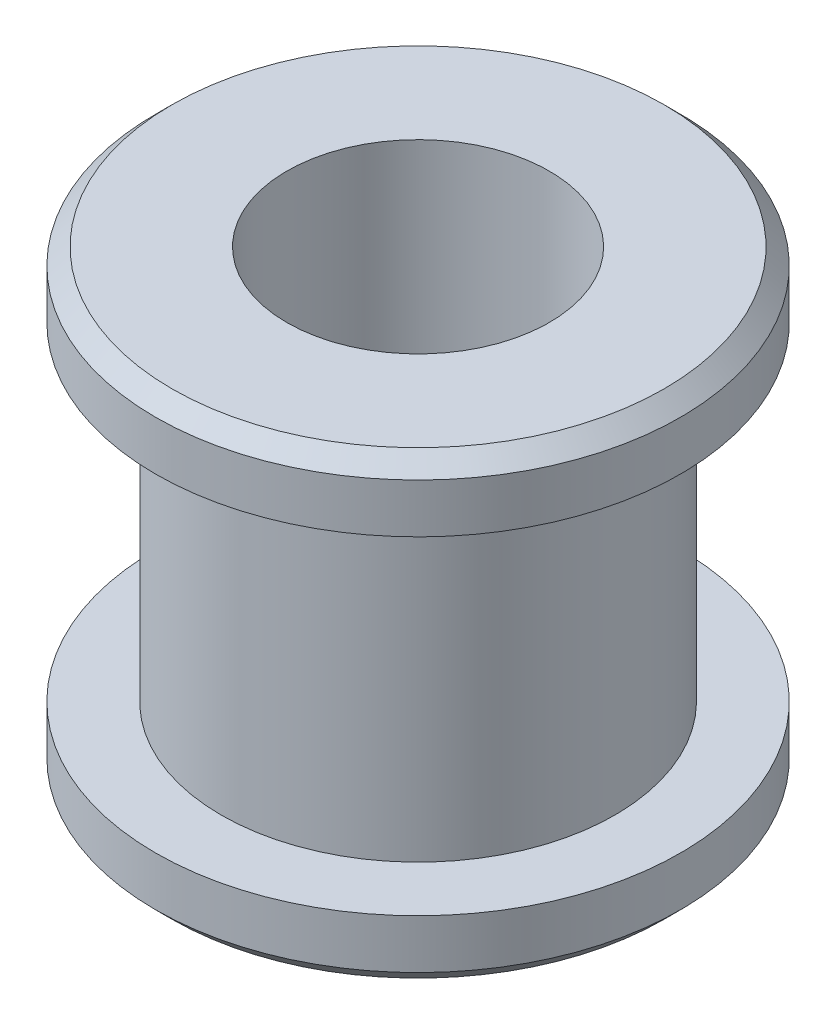
from build123d import *

# Parameters (mm, degrees)
BOSS_EXTRUDE1_DEPTH      = 12
BOSS_EXTRUDE1_DEPTH_BACK = 2
SKETCH1_R                = 6
SKETCH1_R_2              = 4
SKETCH1_3_R              = 8
SKETCH1_3_R_2            = 6
BOSS_EXTRUDE2_DEPTH      = 2
BOSS_EXTRUDE3_START      = 10
SKETCH1_4_R              = 8
SKETCH1_4_R_2            = 6
BOSS_EXTRUDE3_DEPTH      = 2
CHAMFER1_SIZE            = 0.5


with BuildPart() as part:
    # Sketch1 → Boss-Extrude1 (new, two sides: drawn at the far end of the back side and taken through both)
    with BuildSketch(Plane(origin=(0, 0, 0), x_dir=(1, 0, 0), z_dir=(0, 1, 0)).offset(-BOSS_EXTRUDE1_DEPTH_BACK)):
        Circle(SKETCH1_R)
        Circle(SKETCH1_R_2, mode=Mode.SUBTRACT)
    extrude(amount=BOSS_EXTRUDE1_DEPTH + BOSS_EXTRUDE1_DEPTH_BACK)

    # Sketch1_3 → Boss-Extrude2 (add)
    with BuildSketch(Plane(origin=(0, 0, 0), x_dir=(1, 0, 0), z_dir=(0, 1, 0))):
        Circle(SKETCH1_3_R)
        Circle(SKETCH1_3_R_2, mode=Mode.SUBTRACT)
    extrude(amount=-BOSS_EXTRUDE2_DEPTH)

    # Sketch1_4 → Boss-Extrude3 (add)
    with BuildSketch(Plane(origin=(0, 0, 0), x_dir=(1, 0, 0), z_dir=(0, 1, 0)).offset(BOSS_EXTRUDE3_START)):
        Circle(SKETCH1_4_R)
        Circle(SKETCH1_4_R_2, mode=Mode.SUBTRACT)
    extrude(amount=BOSS_EXTRUDE3_DEPTH)

    # Chamfer1
    chamfer1_edges = [part.edges().sort_by_distance(p)[0] for p in [
        (-8, -2, 0),
        (-8, 12, 0),
    ]]
    chamfer(chamfer1_edges, length=CHAMFER1_SIZE)


solid = part.part
